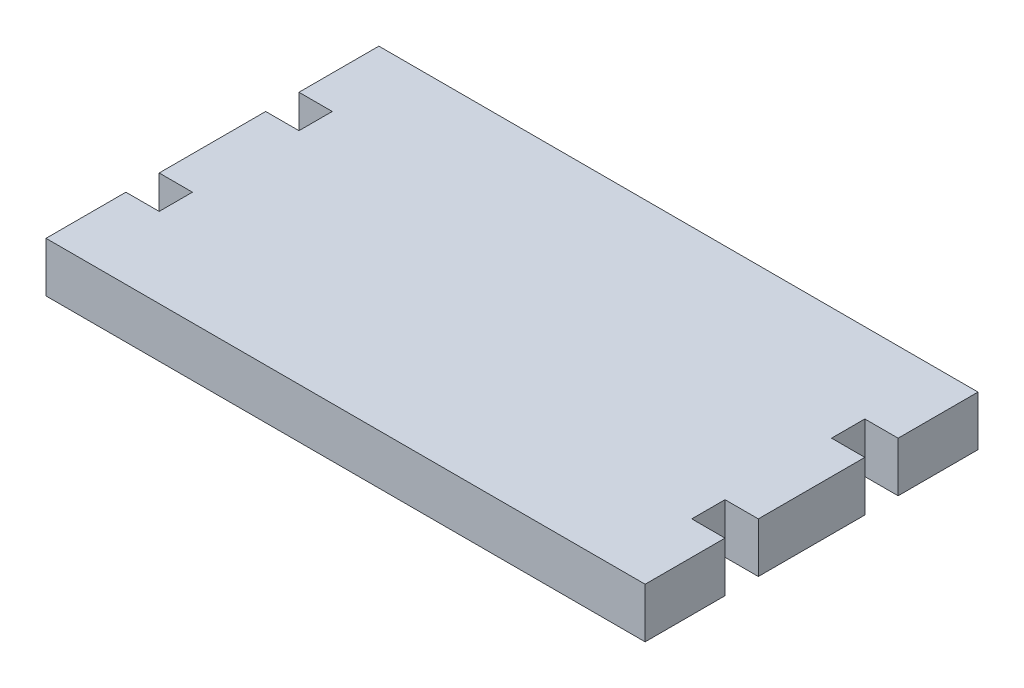
from build123d import *

# Parameters (mm, degrees)
BOSS_EXTRUDE1_DEPTH = 4.7625


with BuildPart() as part:
    # Sketch1 → Boss-Extrude1 (new body)
    with BuildSketch(Plane(origin=(0, 0, 0), x_dir=(1, 0, 0), z_dir=(0, 1, 0))):
        Polygon((0, 24.13), (0, 31.75), (57.15, 31.75), (57.15, 24.13), (53.975, 24.13), (53.975, 20.955), (57.15, 20.955), (57.15, 10.795), (53.975, 10.795), (53.975, 7.62), (57.15, 7.62), (57.15, 0), (0, 0), (0, 7.62), (3.175, 7.62), (3.175, 10.795), (0, 10.795), (0, 20.955), (3.175, 20.955), (3.175, 24.13), align=None)
    extrude(amount=BOSS_EXTRUDE1_DEPTH)


solid = part.part
